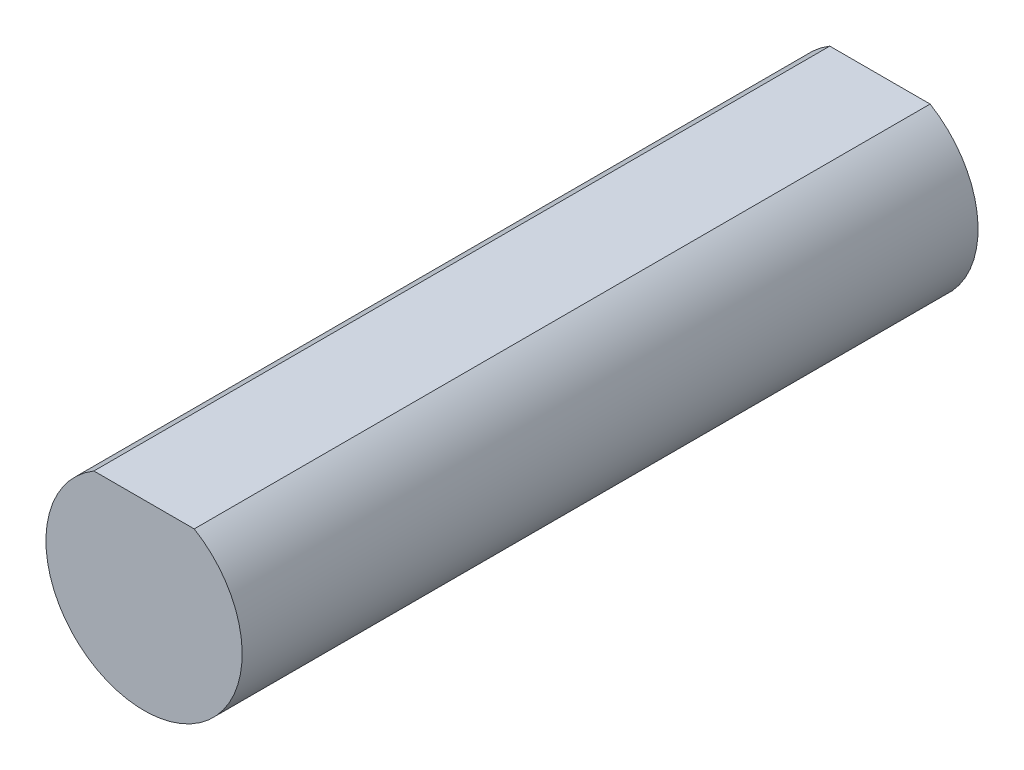
from build123d import *

# Parameters (mm, degrees)
BOSS_EXTRUDE1_DEPTH = 15


with BuildPart() as part:
    # Sketch1 → Boss-Extrude1 (new body)
    with BuildSketch(Plane.XY):
        with BuildLine():
            Line((-1.022665535, 1.718765605), (1.022665535, 1.718765605))
            ThreePointArc((1.022665535, 1.718765605), (0, -2), (-1.022665535, 1.718765605))
        make_face()
    extrude(amount=BOSS_EXTRUDE1_DEPTH)


solid = part.part
